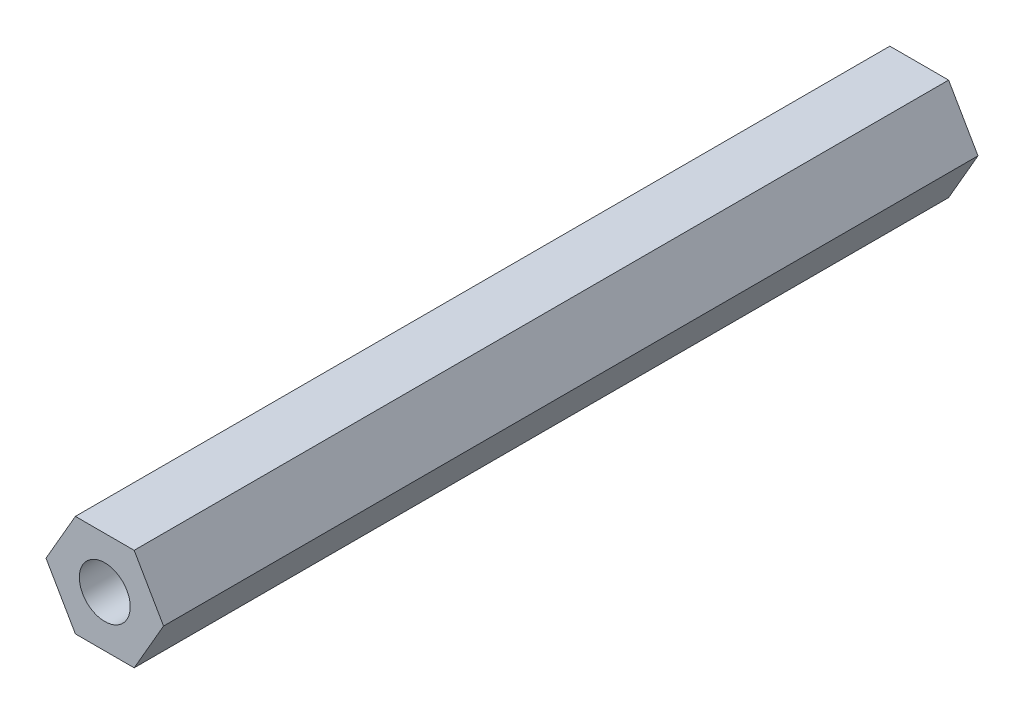
from build123d import *

# Parameters (mm, degrees)
BOSS_EXTRUDE1_DEPTH     = 514.48335
SKETCH2_R               = 3.175
CUT_EXTRUDE1_DEPTH      = 1
CUT_EXTRUDE1_DEPTH_BACK = 515.48335
CUT_EXTRUDE2_DEPTH      = 412.88335


with BuildPart() as part:
    # Sketch1 → Boss-Extrude1 (new body)
    with BuildSketch(Plane.XY):
        Polygon((-7.332348419, 0), (-3.666174209, -6.35), (3.666174209, -6.35), (7.332348419, 0), (3.666174209, 6.35), (-3.666174209, 6.35), align=None)
    extrude(amount=BOSS_EXTRUDE1_DEPTH)

    # Sketch2 → Cut-Extrude1 (cut, two sides)
    with BuildSketch(Plane.XY.offset(514.48335)) as cut_extrude1_sk:
        Circle(SKETCH2_R)
    extrude(amount=CUT_EXTRUDE1_DEPTH, mode=Mode.SUBTRACT)
    extrude(cut_extrude1_sk.sketch, amount=-CUT_EXTRUDE1_DEPTH_BACK, mode=Mode.SUBTRACT)

    # Sketch3 → Cut-Extrude2 (cut)
    with BuildSketch(Plane(origin=(0, 0, 0), x_dir=(-1, 0, 0), z_dir=(0, 0, -1))):
        Polygon((3.666174209, -6.35), (7.332348419, 0), (3.666174209, 6.35), (-3.666174209, 6.35), (-7.332348419, 0), (-3.666174209, -6.35), align=None)
    extrude(amount=-CUT_EXTRUDE2_DEPTH, mode=Mode.SUBTRACT)


solid = part.part
